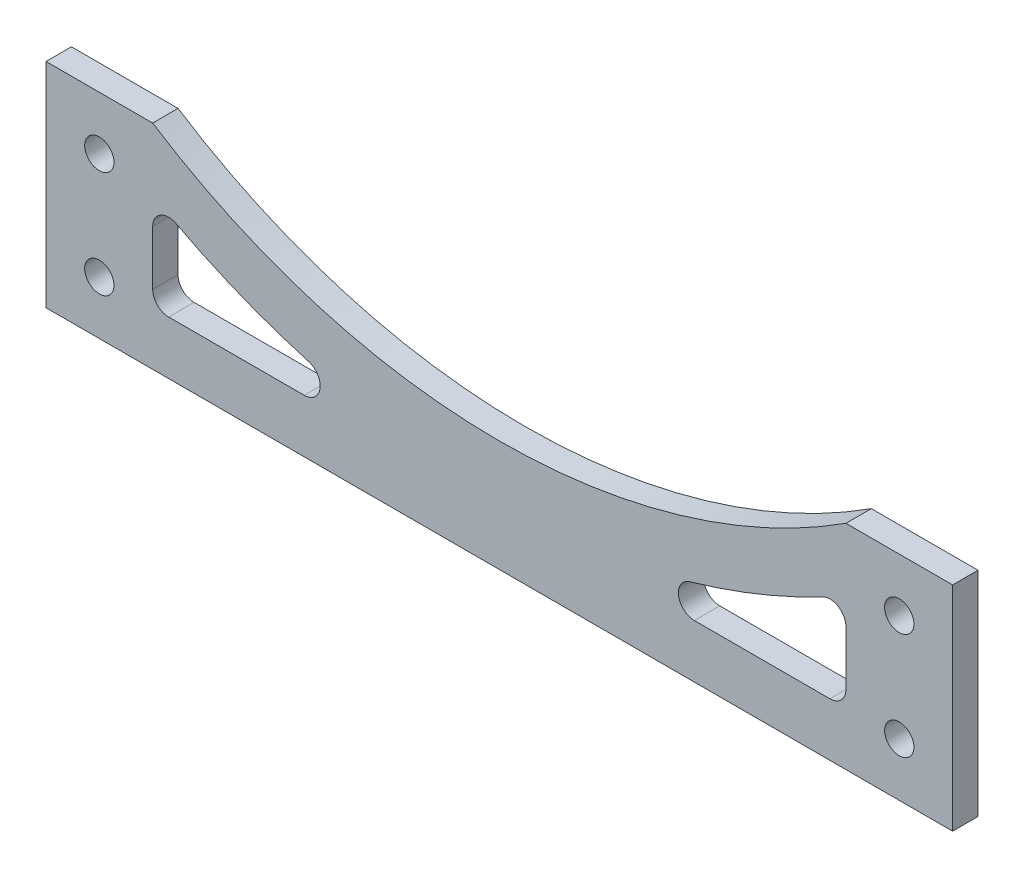
from build123d import *

# Parameters (mm, degrees)
SKETCH1_R           = 2.75
BOSS_EXTRUDE1_DEPTH = 4.7625


with BuildPart() as part:
    # Sketch1 → Boss-Extrude1 (new body)
    with BuildSketch(Plane.XY):
        with BuildLine():
            Line((-85, 0), (85, 0))
            Line((85, 0), (85, 40))
            Line((85, 40), (65, 40))
            ThreePointArc((65, 40), (0, 20.871205009), (-65, 40))
            Line((-65, 40), (-85, 40))
            Line((-85, 40), (-85, 0))
        make_face()
        with Locations((-75, 30)):
            Circle(SKETCH1_R, mode=Mode.SUBTRACT)
        with Locations((-75, 10)):
            Circle(SKETCH1_R, mode=Mode.SUBTRACT)
        with Locations((75, 30)):
            Circle(SKETCH1_R, mode=Mode.SUBTRACT)
        with Locations((75, 10)):
            Circle(SKETCH1_R, mode=Mode.SUBTRACT)
        with BuildLine():
            Line((-65, 23.206426932), (-65, 13))
            ThreePointArc((-65, 13), (-64.121320344, 10.878679656), (-62, 10))
            Line((-62, 10), (-36.578066235, 10))
            ThreePointArc((-36.578066235, 10), (-33.607128783, 12.583429889), (-35.752997072, 15.884312895))
            ThreePointArc((-35.752997072, 15.884312895), (-48.434787426, 20.230949012), (-60.601503759, 25.86051967))
            ThreePointArc((-60.601503759, 25.86051967), (-63.549921172, 25.775034407), (-65, 23.206426932))
        make_face(mode=Mode.SUBTRACT)
        with BuildLine():
            Line((65, 23.206426932), (65, 13))
            ThreePointArc((65, 13), (64.121320344, 10.878679656), (62, 10))
            Line((62, 10), (36.578066235, 10))
            ThreePointArc((36.578066235, 10), (33.607128783, 12.583429889), (35.752997072, 15.884312895))
            ThreePointArc((35.752997072, 15.884312895), (48.434787426, 20.230949012), (60.601503759, 25.86051967))
            ThreePointArc((60.601503759, 25.86051967), (63.549921172, 25.775034407), (65, 23.206426932))
        make_face(mode=Mode.SUBTRACT)
    extrude(amount=BOSS_EXTRUDE1_DEPTH)


solid = part.part
